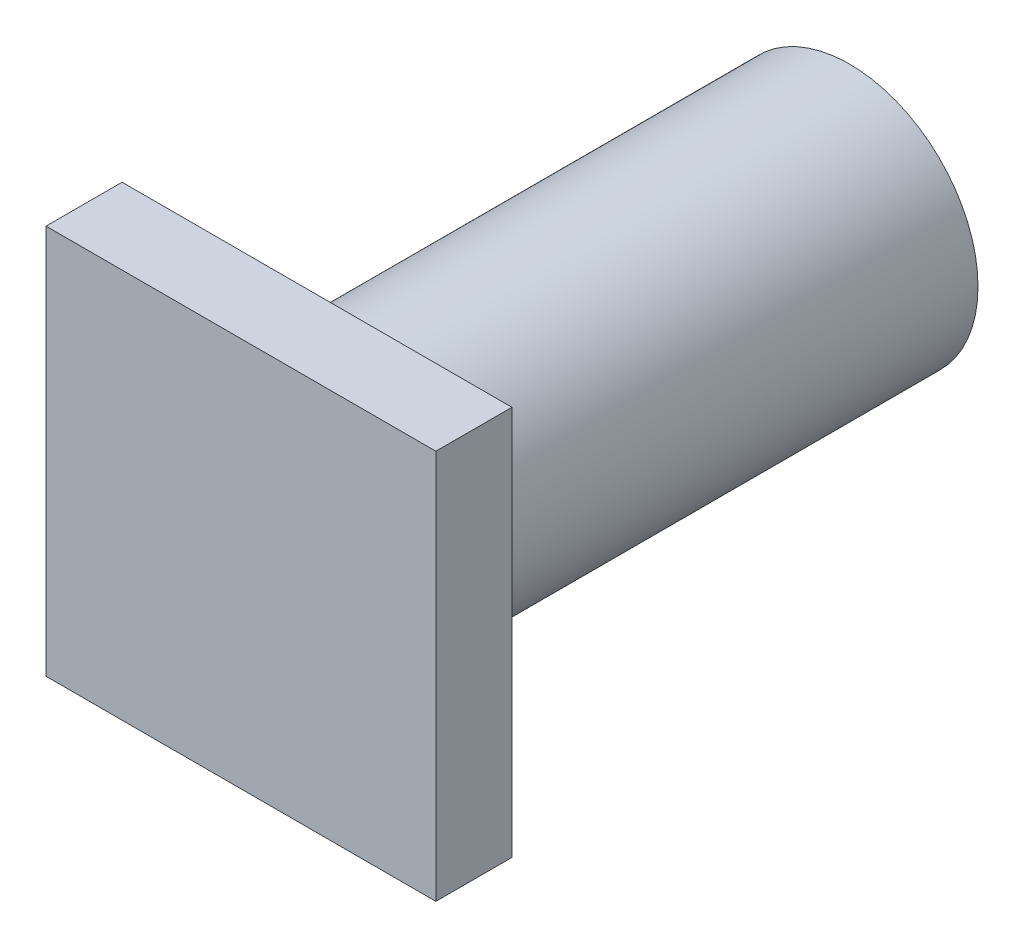
from build123d import *

# Parameters (mm, degrees)
SKETCH1_R           = 16.892448346
BOSS_EXTRUDE1_DEPTH = 70
SKETCH2_W           = 51.249127752
SKETCH2_H           = 51.249127751
BOSS_EXTRUDE2_DEPTH = 10


with BuildPart() as part:
    # Sketch1 → Boss-Extrude1 (new body)
    with BuildSketch(Plane.XY):
        with Locations((-8.123318292, -5.927826862)):
            Circle(SKETCH1_R)
    extrude(amount=BOSS_EXTRUDE1_DEPTH)

    # Sketch2 → Boss-Extrude2 (add)
    with BuildSketch(Plane.XY.offset(70)):
        with Locations((-8.123318292, -5.927826862)):
            Rectangle(SKETCH2_W, SKETCH2_H)
    extrude(amount=BOSS_EXTRUDE2_DEPTH)


solid = part.part
